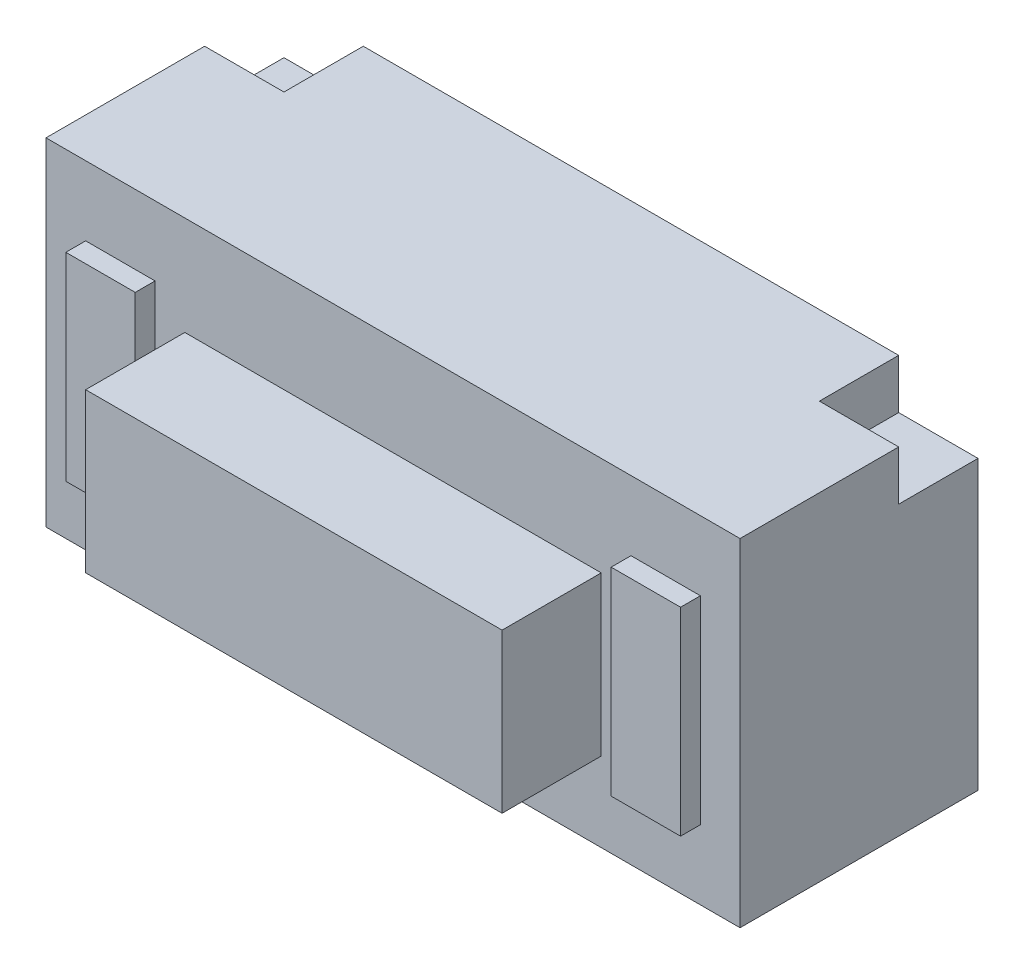
from build123d import *

# Parameters (mm, degrees)
ESQUISSE1_W             = 7
ESQUISSE1_H             = 2.4
BOSS_EXTRU_1_DEPTH      = 3.4
ESQUISSE2_W             = 0.8
ESQUISSE2_H             = 0.8
ENL_V_MAT_EXTRU_1_DEPTH = 0.5
ESQUISSE3_W             = 0.7
ESQUISSE3_H             = 2
ESQUISSE3_W_2           = 4.2
ESQUISSE3_H_2           = 1.6
BOSS_EXTRU_2_DEPTH      = 0.2
ESQUISSE4_W             = 4.2
ESQUISSE4_H             = 1.6
BOSS_EXTRU_3_DEPTH      = 0.8


with BuildPart() as part:
    # Esquisse1 → Boss.-Extru.1 (new body)
    with BuildSketch(Plane(origin=(0, 0, 0), x_dir=(1, 0, 0), z_dir=(0, 1, 0))):
        Rectangle(ESQUISSE1_W, ESQUISSE1_H)
    extrude(amount=BOSS_EXTRU_1_DEPTH)

    # Esquisse2 → Enlèv. mat.-Extru.1 (cut)
    with BuildSketch(Plane(origin=(0, 3.4, 0), x_dir=(1, 0, 0), z_dir=(0, 1, 0))):
        with Locations((-3.1, 0.8)):
            Rectangle(ESQUISSE2_W, ESQUISSE2_H)
        with Locations((3.1, 0.8)):
            Rectangle(ESQUISSE2_W, ESQUISSE2_H)
    extrude(amount=-ENL_V_MAT_EXTRU_1_DEPTH, mode=Mode.SUBTRACT)

    # Esquisse3 → Boss.-Extru.2 (add)
    with BuildSketch(Plane.XY.offset(1.2)):
        with Locations((-2.75, 1.7)):
            Rectangle(ESQUISSE3_W, ESQUISSE3_H)
        with Locations((0, 1.6)):
            Rectangle(ESQUISSE3_W_2, ESQUISSE3_H_2)
        with Locations((2.75, 1.7)):
            Rectangle(ESQUISSE3_W, ESQUISSE3_H)
    extrude(amount=BOSS_EXTRU_2_DEPTH)

    # Esquisse4 → Boss.-Extru.3 (add)
    with BuildSketch(Plane.XY.offset(1.4)):
        with Locations((0, 1.6)):
            Rectangle(ESQUISSE4_W, ESQUISSE4_H)
    extrude(amount=BOSS_EXTRU_3_DEPTH)


solid = part.part
